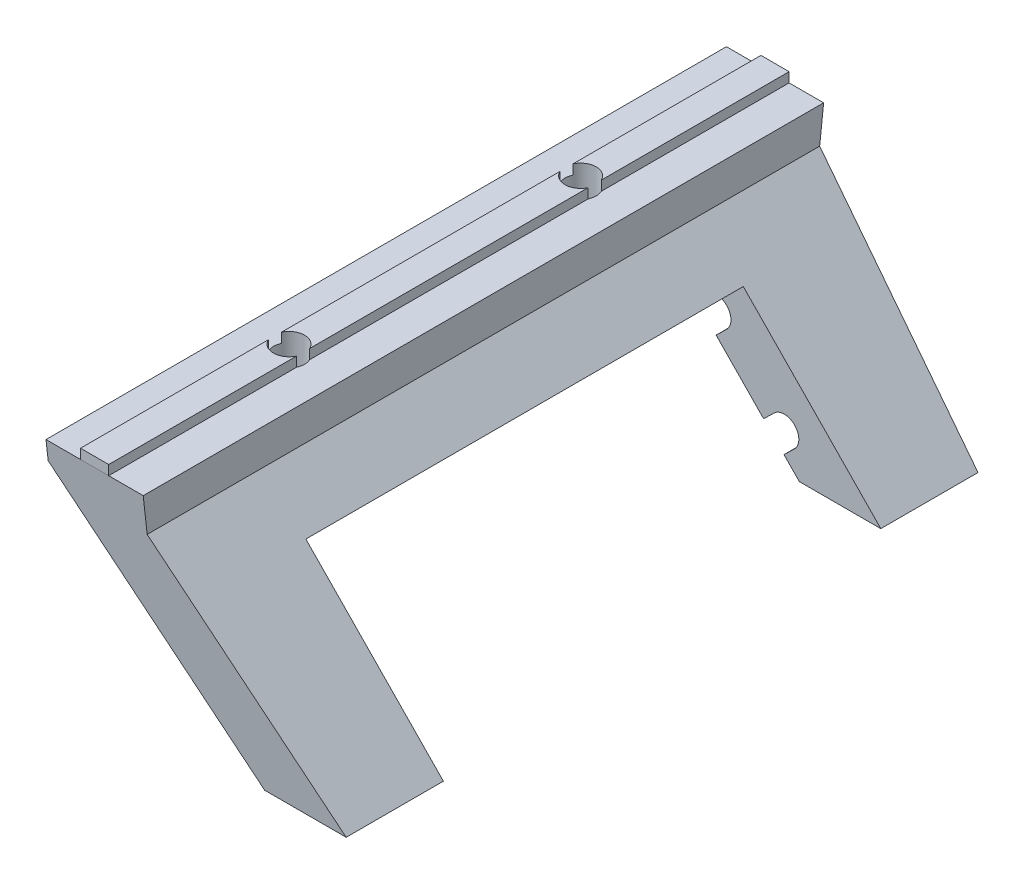
from build123d import *

# Parameters (mm, degrees)
MAIN_DEPTH                   = 35
SIDECUT_DEPTH                = 9.382441068
SIDECUT_DEPTH_BACK           = 21
SKETCH5_W                    = 45
SKETCH5_H                    = 60
CENTRALCUT_DEPTH             = 9.382441068
CENTRALCUT_DEPTH_BACK        = 21
SKETCH3_R                    = 1.6
MAKERBEAMFIXHOLES_DEPTH      = 1
MAKERBEAMFIXHOLES_DEPTH_BACK = 24.5
ROLLERSUPPORTHOLES_DEPTH     = 30
LPATTERN1_COUNT              = 3
LPATTERN1_PITCH              = 10
SKETCH6_R                    = 4.25
SCREWHOLE_DEPTH              = 3


with BuildPart() as part:
    # Sketch1 → Main (new body, symmetric)
    with BuildSketch(Plane.XY):
        Polygon((-10, 22.5), (-10, 18.842002095), (8.382441068, 0), (0, 0), (-20, 20.5), (-20, 22.5), (-16.45, 22.5), (-16.45, 23.5), (-13.55, 23.5), (-13.55, 22.5), align=None)
    extrude(amount=MAIN_DEPTH, both=True)

    # Sketch2 → SideCut (cut, two sides)
    with BuildSketch(Plane(origin=(0, 12.071067812, 0), x_dir=(0, 0, 1), z_dir=(1, 0, 0))) as sidecut_sk:
        Polygon((-35, -10.428932188), (-32.5, 12.071067812), (-35, 12.071067812), align=None)
        Polygon((35, -10.428932188), (35, 12.071067812), (32.5, 12.071067812), align=None)
    extrude(amount=SIDECUT_DEPTH, mode=Mode.SUBTRACT)
    extrude(sidecut_sk.sketch, amount=-SIDECUT_DEPTH_BACK, mode=Mode.SUBTRACT)

    # Sketch5 → CentralCut (cut, two sides)
    with BuildSketch(Plane(origin=(0, 0, 0), x_dir=(0, 0, 1), z_dir=(1, 0, 0))) as centralcut_sk:
        with Locations((0, 15.5)):
            Rectangle(SKETCH5_W, SKETCH5_H)
    extrude(amount=CENTRALCUT_DEPTH, mode=Mode.SUBTRACT)
    extrude(centralcut_sk.sketch, amount=-CENTRALCUT_DEPTH_BACK, mode=Mode.SUBTRACT)

    # Sketch3 → MakerBeamFixHoles (cut, two sides)
    with BuildSketch(Plane(origin=(0, 23.5, 0), x_dir=(1, 0, 0), z_dir=(0, 1, 0))) as makerbeamfixholes_sk:
        with Locations((-15, 15)):
            Circle(SKETCH3_R)
        with Locations((-15, -15)):
            Circle(SKETCH3_R)
    extrude(amount=MAKERBEAMFIXHOLES_DEPTH, mode=Mode.SUBTRACT)
    extrude(makerbeamfixholes_sk.sketch, amount=-MAKERBEAMFIXHOLES_DEPTH_BACK, mode=Mode.SUBTRACT)

    # Sketch4 → RollerSupportHoles (cut, symmetric)
    with BuildSketch(Plane.XY):
        with BuildLine():
            Line((-10.654722203, 10.921090258), (-8.559750647, 8.773744413))
            Line((-8.559750647, 8.773744413), (-7.486077724, 9.821230191))
            ThreePointArc((-7.486077724, 9.821230191), (-7.45989058, 11.942388892), (-9.58104928, 11.968576036))
            Line((-9.58104928, 11.968576036), (-10.654722203, 10.921090258))
        make_face()
    rollersupportholes = extrude(amount=ROLLERSUPPORTHOLES_DEPTH, both=True, mode=Mode.SUBTRACT)

    # LPattern1: RollerSupportHoles ×3
    with Locations(*[Vector(0.698323852, -0.715781948, 0) * (i * LPATTERN1_PITCH) for i in range(1, LPATTERN1_COUNT)]):
        add(rollersupportholes, mode=Mode.SUBTRACT)

    # Sketch6 → ScrewHole (cut)
    with BuildSketch(Plane(origin=(0, 14.5, 0), x_dir=(-1, 0, 0), z_dir=(0, -1, 0))):
        with Locations((15, 15)):
            Circle(SKETCH6_R)
        with Locations((15, -15)):
            Circle(SKETCH6_R)
    extrude(amount=-SCREWHOLE_DEPTH, mode=Mode.SUBTRACT)


solid = part.part
